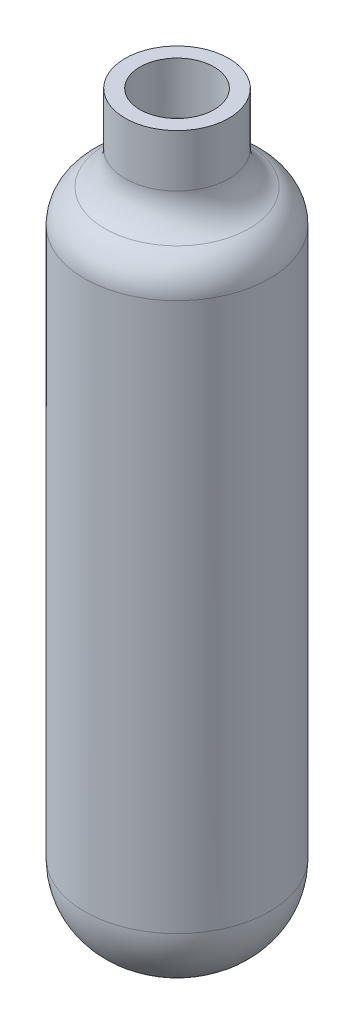
from build123d import *

# Parameters (mm, degrees)
VERRUNDUNG1_R = 20
VERRUNDUNG4_R = 10
VERRUNDUNG5_R = 10


with BuildPart() as part:
    # Skizze1 → Rotation1 (revolve)
    with BuildSketch(Plane.XY):
        Polygon((0, 0), (25, 0), (25, 178), (14, 178), (14, 200), (10, 200), (10, 177), (13, 177), (24, 177), (24, 1), (0, 1), align=None)
    revolve(axis=Axis((0, 0, 0), (0, 1, 0)))

    # Verrundung1
    verrundung1_edges = [part.edges().sort_by_distance(p)[0] for p in [
        (-25, 0, 0),
        (-24, 1, 0),
    ]]
    fillet(verrundung1_edges, radius=VERRUNDUNG1_R)

    # Verrundung4
    verrundung4_edges = [part.edges().sort_by_distance(p)[0] for p in [
        (-25, 178, 0),
        (-24, 177, 0),
    ]]
    fillet(verrundung4_edges, radius=VERRUNDUNG4_R)

    # Verrundung5
    verrundung5_edges = [part.edges().sort_by_distance(p)[0] for p in [
        (-14, 178, 0),
        (-10, 177, 0),
    ]]
    fillet(verrundung5_edges, radius=VERRUNDUNG5_R)


solid = part.part
